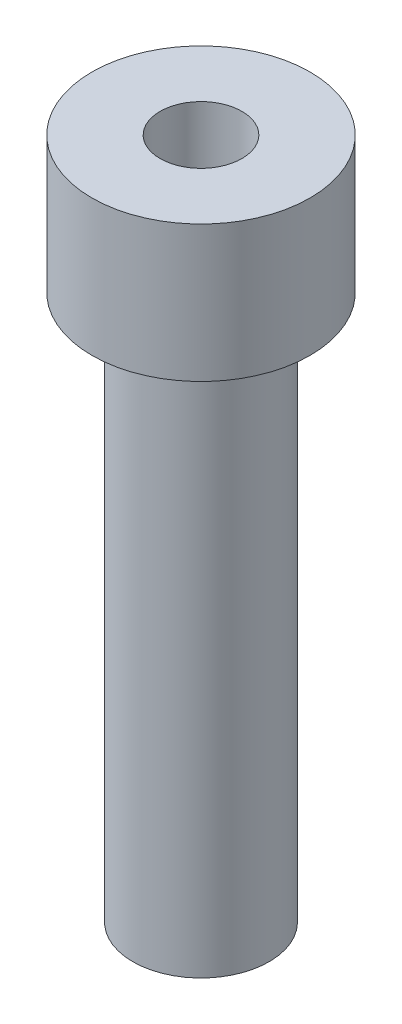
from build123d import *

# Parameters (mm, degrees)
SKETCH1_R           = 2.5
BOSS_EXTRUDE1_DEPTH = 20
SKETCH2_R           = 4
BOSS_EXTRUDE2_DEPTH = 5
SKETCH3_R           = 1.5
CUT_EXTRUDE1_DEPTH  = 3


with BuildPart() as part:
    # Sketch1 → Boss-Extrude1 (new body)
    with BuildSketch(Plane(origin=(0, 0, 0), x_dir=(1, 0, 0), z_dir=(0, 1, 0))):
        Circle(SKETCH1_R)
    extrude(amount=BOSS_EXTRUDE1_DEPTH)

    # Sketch2 → Boss-Extrude2 (add)
    with BuildSketch(Plane(origin=(0, 20, 0), x_dir=(1, 0, 0), z_dir=(0, 1, 0))):
        Circle(SKETCH2_R)
    extrude(amount=BOSS_EXTRUDE2_DEPTH)

    # Sketch3 → Cut-Extrude1 (cut)
    with BuildSketch(Plane(origin=(0, 25, 0), x_dir=(1, 0, 0), z_dir=(0, 1, 0))):
        Circle(SKETCH3_R)
    extrude(amount=-CUT_EXTRUDE1_DEPTH, mode=Mode.SUBTRACT)


solid = part.part
